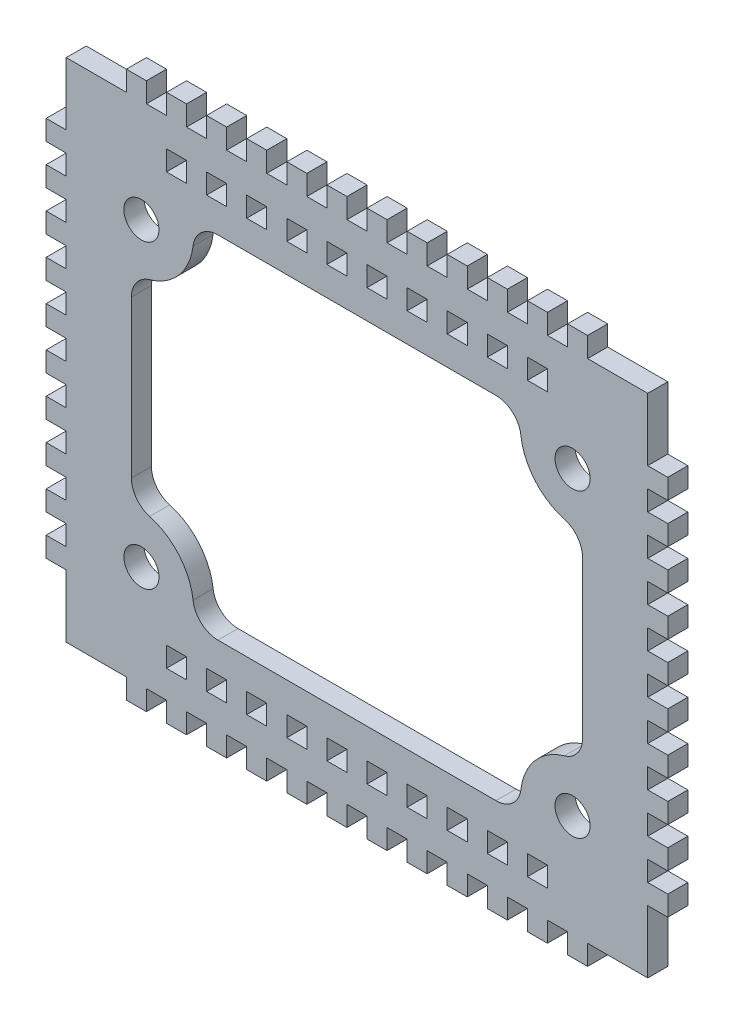
from build123d import *

# Parameters (mm, degrees)
SKETCH1_W           = 116
SKETCH1_H           = 101
SKETCH1_R           = 3.5
BOSS_EXTRUDE1_DEPTH = 4
SKETCH3_W           = 4
SKETCH3_H           = 4
CUT_EXTRUDE2_DEPTH  = 4
FILLET1_R           = 5
FILLET2_R           = 5
FILLET3_R           = 5
FILLET4_R           = 5
FILLET5_R           = 5
FILLET6_R           = 5
FILLET7_R           = 5
FILLET8_R           = 5
SKETCH4_W           = 4
SKETCH4_H           = 4
BOSS_EXTRUDE2_DEPTH = 4
SKETCH5_W           = 4
SKETCH5_H           = 4
BOSS_EXTRUDE3_DEPTH = 4


with BuildPart() as part:
    # Sketch1 → Boss-Extrude1 (new body)
    with BuildSketch(Plane.XY):
        Rectangle(SKETCH1_W, SKETCH1_H)
        with Locations((-43, 30)):
            Circle(SKETCH1_R, mode=Mode.SUBTRACT)
        with Locations((43, 30)):
            Circle(SKETCH1_R, mode=Mode.SUBTRACT)
        with Locations((43, -30)):
            Circle(SKETCH1_R, mode=Mode.SUBTRACT)
        with Locations((-43, -30)):
            Circle(SKETCH1_R, mode=Mode.SUBTRACT)
        with BuildLine():
            Line((-45, -20), (-45, 20))
            ThreePointArc((-45, 20), (-35.246947165, 24.497557732), (-33, 35))
            Line((-33, 35), (33, 35))
            ThreePointArc((33, 35), (35.246947165, 24.497557732), (45, 20))
            Line((45, 20), (45, -20))
            ThreePointArc((45, -20), (35.246947165, -24.497557732), (33, -35))
            Line((33, -35), (-33, -35))
            ThreePointArc((-33, -35), (-35.246947165, -24.497557732), (-45, -20))
        make_face(mode=Mode.SUBTRACT)
    extrude(amount=BOSS_EXTRUDE1_DEPTH)

    # Sketch3 → Cut-Extrude2 (cut)
    with BuildSketch(Plane.XY.offset(4)):
        with Locations((-12, 42.75)):
            Rectangle(SKETCH3_W, SKETCH3_H)
        with Locations((-20, 42.75)):
            Rectangle(SKETCH3_W, SKETCH3_H)
        with Locations((-28, 42.75)):
            Rectangle(SKETCH3_W, SKETCH3_H)
        with Locations((-12, -43)):
            Rectangle(SKETCH3_W, SKETCH3_H)
        with Locations((-4, -43)):
            Rectangle(SKETCH3_W, SKETCH3_H)
        with Locations((-36, 42.75)):
            Rectangle(SKETCH3_W, SKETCH3_H)
        with Locations((4, 42.75)):
            Rectangle(SKETCH3_W, SKETCH3_H)
        with Locations((36, 42.75)):
            Rectangle(SKETCH3_W, SKETCH3_H)
        with Locations((28, 42.75)):
            Rectangle(SKETCH3_W, SKETCH3_H)
        with Locations((20, 42.75)):
            Rectangle(SKETCH3_W, SKETCH3_H)
        with Locations((12, 42.75)):
            Rectangle(SKETCH3_W, SKETCH3_H)
        with Locations((-4, 42.75)):
            Rectangle(SKETCH3_W, SKETCH3_H)
        with Locations((-20, -43)):
            Rectangle(SKETCH3_W, SKETCH3_H)
        with Locations((-28, -43)):
            Rectangle(SKETCH3_W, SKETCH3_H)
        with Locations((-36, -43)):
            Rectangle(SKETCH3_W, SKETCH3_H)
        with Locations((36, -43)):
            Rectangle(SKETCH3_W, SKETCH3_H)
        with Locations((28, -43)):
            Rectangle(SKETCH3_W, SKETCH3_H)
        with Locations((20, -43)):
            Rectangle(SKETCH3_W, SKETCH3_H)
        with Locations((12, -43)):
            Rectangle(SKETCH3_W, SKETCH3_H)
        with Locations((4, -43)):
            Rectangle(SKETCH3_W, SKETCH3_H)
    extrude(amount=-CUT_EXTRUDE2_DEPTH, mode=Mode.SUBTRACT)

    # Fillet1
    fillet1_edges = [part.edges().sort_by_distance(p)[0] for p in [
        (-45, 20, 2),
    ]]
    fillet(fillet1_edges, radius=FILLET1_R)

    # Fillet2
    fillet2_edges = [part.edges().sort_by_distance(p)[0] for p in [
        (-33, 35, 2),
    ]]
    fillet(fillet2_edges, radius=FILLET2_R)

    # Fillet3
    fillet3_edges = [part.edges().sort_by_distance(p)[0] for p in [
        (33, 35, 2),
    ]]
    fillet(fillet3_edges, radius=FILLET3_R)

    # Fillet4
    fillet4_edges = [part.edges().sort_by_distance(p)[0] for p in [
        (45, 20, 2),
    ]]
    fillet(fillet4_edges, radius=FILLET4_R)

    # Fillet5
    fillet5_edges = [part.edges().sort_by_distance(p)[0] for p in [
        (33, -35, 2),
    ]]
    fillet(fillet5_edges, radius=FILLET5_R)

    # Fillet6
    fillet6_edges = [part.edges().sort_by_distance(p)[0] for p in [
        (45, -20, 2),
    ]]
    fillet(fillet6_edges, radius=FILLET6_R)

    # Fillet7
    fillet7_edges = [part.edges().sort_by_distance(p)[0] for p in [
        (-45, -20, 2),
    ]]
    fillet(fillet7_edges, radius=FILLET7_R)

    # Fillet8
    fillet8_edges = [part.edges().sort_by_distance(p)[0] for p in [
        (-33, -35, 2),
    ]]
    fillet(fillet8_edges, radius=FILLET8_R)

    # Sketch4 → Boss-Extrude2 (add)
    with BuildSketch(Plane.XY.offset(4)):
        with Locations((-60, 4)):
            Rectangle(SKETCH4_W, SKETCH4_H)
        with Locations((-60, 12)):
            Rectangle(SKETCH4_W, SKETCH4_H)
        with Locations((-60, 20)):
            Rectangle(SKETCH4_W, SKETCH4_H)
        with Locations((-60, 28)):
            Rectangle(SKETCH4_W, SKETCH4_H)
        with Locations((-60, 36)):
            Rectangle(SKETCH4_W, SKETCH4_H)
        with Locations((-60, -36)):
            Rectangle(SKETCH4_W, SKETCH4_H)
        with Locations((-60, -28)):
            Rectangle(SKETCH4_W, SKETCH4_H)
        with Locations((-60, -20)):
            Rectangle(SKETCH4_W, SKETCH4_H)
        with Locations((-60, -12)):
            Rectangle(SKETCH4_W, SKETCH4_H)
        with Locations((-60, -4)):
            Rectangle(SKETCH4_W, SKETCH4_H)
        with Locations((60, -4)):
            Rectangle(SKETCH4_W, SKETCH4_H)
        with Locations((60, -12)):
            Rectangle(SKETCH4_W, SKETCH4_H)
        with Locations((60, -20)):
            Rectangle(SKETCH4_W, SKETCH4_H)
        with Locations((60, -28)):
            Rectangle(SKETCH4_W, SKETCH4_H)
        with Locations((60, -36)):
            Rectangle(SKETCH4_W, SKETCH4_H)
        with Locations((60, 36)):
            Rectangle(SKETCH4_W, SKETCH4_H)
        with Locations((60, 28)):
            Rectangle(SKETCH4_W, SKETCH4_H)
        with Locations((60, 20)):
            Rectangle(SKETCH4_W, SKETCH4_H)
        with Locations((60, 12)):
            Rectangle(SKETCH4_W, SKETCH4_H)
        with Locations((60, 4)):
            Rectangle(SKETCH4_W, SKETCH4_H)
    extrude(amount=-BOSS_EXTRUDE2_DEPTH)

    # Sketch5 → Boss-Extrude3 (add)
    with BuildSketch(Plane(origin=(0, 0, 0), x_dir=(-1, 0, 0), z_dir=(0, 0, -1))):
        with Locations((-4, 52.5)):
            Rectangle(SKETCH5_W, SKETCH5_H)
        with Locations((-12, 52.5)):
            Rectangle(SKETCH5_W, SKETCH5_H)
        with Locations((-20, 52.5)):
            Rectangle(SKETCH5_W, SKETCH5_H)
        with Locations((-28, 52.5)):
            Rectangle(SKETCH5_W, SKETCH5_H)
        with Locations((-36, 52.5)):
            Rectangle(SKETCH5_W, SKETCH5_H)
        with Locations((-44, 52.5)):
            Rectangle(SKETCH5_W, SKETCH5_H)
        with Locations((44, 52.5)):
            Rectangle(SKETCH5_W, SKETCH5_H)
        with Locations((36, 52.5)):
            Rectangle(SKETCH5_W, SKETCH5_H)
        with Locations((28, 52.5)):
            Rectangle(SKETCH5_W, SKETCH5_H)
        with Locations((20, 52.5)):
            Rectangle(SKETCH5_W, SKETCH5_H)
        with Locations((12, 52.5)):
            Rectangle(SKETCH5_W, SKETCH5_H)
        with Locations((4, 52.5)):
            Rectangle(SKETCH5_W, SKETCH5_H)
        with Locations((4, -52.5)):
            Rectangle(SKETCH5_W, SKETCH5_H)
        with Locations((12, -52.5)):
            Rectangle(SKETCH5_W, SKETCH5_H)
        with Locations((20, -52.5)):
            Rectangle(SKETCH5_W, SKETCH5_H)
        with Locations((28, -52.5)):
            Rectangle(SKETCH5_W, SKETCH5_H)
        with Locations((36, -52.5)):
            Rectangle(SKETCH5_W, SKETCH5_H)
        with Locations((44, -52.5)):
            Rectangle(SKETCH5_W, SKETCH5_H)
        with Locations((-44, -52.5)):
            Rectangle(SKETCH5_W, SKETCH5_H)
        with Locations((-36, -52.5)):
            Rectangle(SKETCH5_W, SKETCH5_H)
        with Locations((-28, -52.5)):
            Rectangle(SKETCH5_W, SKETCH5_H)
        with Locations((-20, -52.5)):
            Rectangle(SKETCH5_W, SKETCH5_H)
        with Locations((-12, -52.5)):
            Rectangle(SKETCH5_W, SKETCH5_H)
        with Locations((-4, -52.5)):
            Rectangle(SKETCH5_W, SKETCH5_H)
    extrude(amount=-BOSS_EXTRUDE3_DEPTH)


solid = part.part
